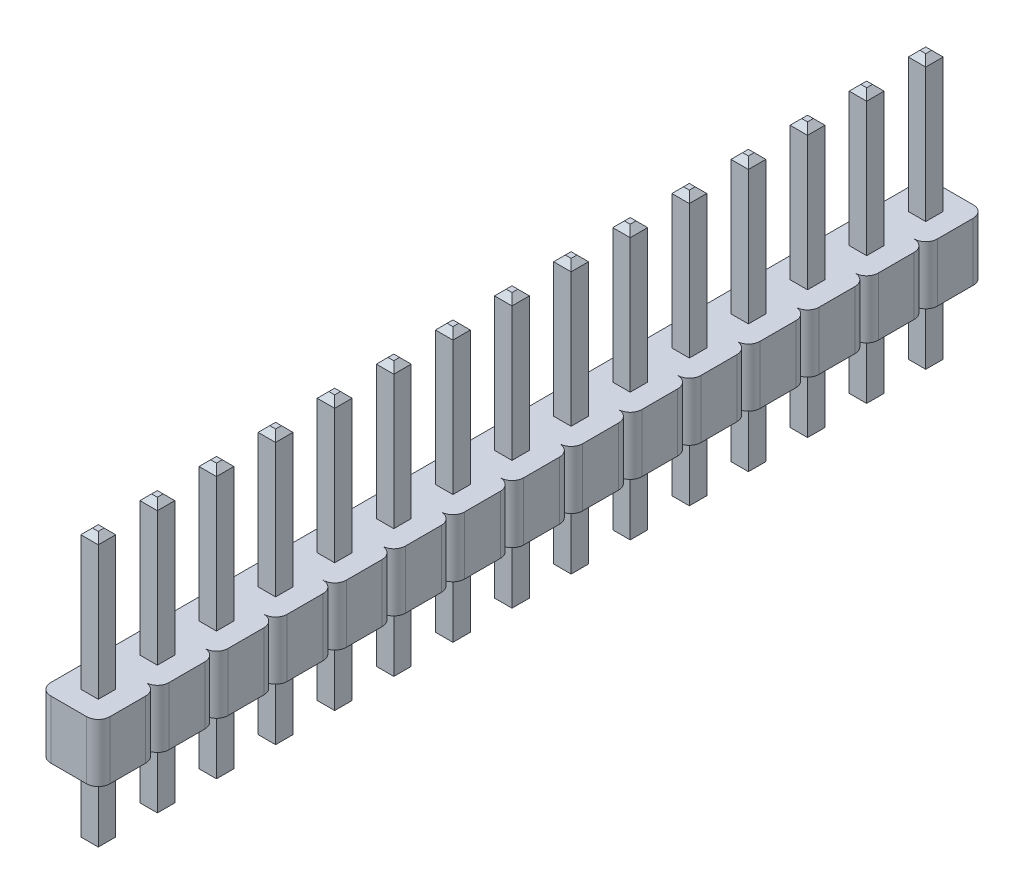
from build123d import *

# Parameters (mm, degrees)
BOSS_EXTRUDE1_DEPTH        = 2.5
LPATTERN1_COUNT            = 15
LPATTERN1_PITCH            = 2.54
BOSS_EXTRUDE2_START        = -3.25
SKETCH2_W                  = 0.75
SKETCH2_H                  = 0.75
BOSS_EXTRUDE2_DEPTH        = 11.75
CHAMFER1_SIZE              = 0.25
LPATTERN2_COUNT            = 15
LPATTERN2_PITCH            = 2.54
CHAMFER1_OF_LPATTERN2_SIZE = 0.25


with BuildPart() as part:
    # Sketch1 → Boss-Extrude1 (new body)
    with BuildSketch(Plane(origin=(0, 0, 0), x_dir=(-1, 0, 0), z_dir=(0, 1, 0))):
        with BuildLine():
            Line((-0.77, 1.27), (0.77, 1.27))
            ThreePointArc((0.77, 1.27), (1.123553391, 1.123553391), (1.27, 0.77))
            Line((1.27, 0.77), (1.27, -0.77))
            ThreePointArc((1.27, -0.77), (1.123553391, -1.123553391), (0.77, -1.27))
            Line((0.77, -1.27), (-0.77, -1.27))
            ThreePointArc((-0.77, -1.27), (-1.123553391, -1.123553391), (-1.27, -0.77))
            Line((-1.27, -0.77), (-1.27, 0.77))
            ThreePointArc((-1.27, 0.77), (-1.123553391, 1.123553391), (-0.77, 1.27))
        make_face()
    boss_extrude1 = extrude(amount=BOSS_EXTRUDE1_DEPTH)

    # LPattern1: Boss-Extrude1 ×15
    with Locations(*[(0, 0, i * LPATTERN1_PITCH) for i in range(1, LPATTERN1_COUNT)]):
        add(boss_extrude1)

    # Sketch2 → Boss-Extrude2 (add)
    with BuildSketch(Plane(origin=(0, 0, 0), x_dir=(-1, 0, 0), z_dir=(0, 1, 0)).offset(BOSS_EXTRUDE2_START)):
        Rectangle(SKETCH2_W, SKETCH2_H)
    boss_extrude2 = extrude(amount=BOSS_EXTRUDE2_DEPTH)

    # Chamfer1
    chamfer1_edges = [part.edges().sort_by_distance(p)[0] for p in [
        (0, -3.25, 0.375),
        (-0.375, -3.25, 0),
        (0.375, -3.25, 0),
        (0, -3.25, -0.375),
        (0, 8.5, 0.375),
        (-0.375, 8.5, 0),
        (0, 8.5, -0.375),
        (0.375, 8.5, 0),
    ]]
    chamfer(chamfer1_edges, length=CHAMFER1_SIZE)

    # LPattern2: Boss-Extrude2 ×15
    with Locations(*[(0, 0, i * LPATTERN2_PITCH) for i in range(1, LPATTERN2_COUNT)]):
        add(boss_extrude2)

    # Chamfer1 of LPattern2
    chamfer1_of_lpattern2_edges = [part.edges().sort_by_distance(p)[0] for p in [
        (0, -3.25, 2.915),
        (-0.375, -3.25, 2.54),
        (0.375, -3.25, 2.54),
        (0, -3.25, 2.165),
        (0, 8.5, 2.915),
        (-0.375, 8.5, 2.54),
        (0, 8.5, 2.165),
        (0.375, 8.5, 2.54),
        (0, -3.25, 5.455),
        (-0.375, -3.25, 5.08),
        (0.375, -3.25, 5.08),
        (0, -3.25, 4.705),
        (0, 8.5, 5.455),
        (-0.375, 8.5, 5.08),
        (0, 8.5, 4.705),
        (0.375, 8.5, 5.08),
        (0, -3.25, 7.995),
        (-0.375, -3.25, 7.62),
        (0.375, -3.25, 7.62),
        (0, -3.25, 7.245),
        (0, 8.5, 7.995),
        (-0.375, 8.5, 7.62),
        (0, 8.5, 7.245),
        (0.375, 8.5, 7.62),
        (0, -3.25, 10.535),
        (-0.375, -3.25, 10.16),
        (0.375, -3.25, 10.16),
        (0, -3.25, 9.785),
        (0, 8.5, 10.535),
        (-0.375, 8.5, 10.16),
        (0, 8.5, 9.785),
        (0.375, 8.5, 10.16),
        (0, -3.25, 13.075),
        (-0.375, -3.25, 12.7),
        (0.375, -3.25, 12.7),
        (0, -3.25, 12.325),
        (0, 8.5, 13.075),
        (-0.375, 8.5, 12.7),
        (0, 8.5, 12.325),
        (0.375, 8.5, 12.7),
        (0, -3.25, 15.615),
        (-0.375, -3.25, 15.24),
        (0.375, -3.25, 15.24),
        (0, -3.25, 14.865),
        (0, 8.5, 15.615),
        (-0.375, 8.5, 15.24),
        (0, 8.5, 14.865),
        (0.375, 8.5, 15.24),
        (0, -3.25, 18.155),
        (-0.375, -3.25, 17.78),
        (0.375, -3.25, 17.78),
        (0, -3.25, 17.405),
        (0, 8.5, 18.155),
        (-0.375, 8.5, 17.78),
        (0, 8.5, 17.405),
        (0.375, 8.5, 17.78),
        (0, -3.25, 20.695),
        (-0.375, -3.25, 20.32),
        (0.375, -3.25, 20.32),
        (0, -3.25, 19.945),
        (0, 8.5, 20.695),
        (-0.375, 8.5, 20.32),
        (0, 8.5, 19.945),
        (0.375, 8.5, 20.32),
        (0, -3.25, 23.235),
        (-0.375, -3.25, 22.86),
        (0.375, -3.25, 22.86),
        (0, -3.25, 22.485),
        (0, 8.5, 23.235),
        (-0.375, 8.5, 22.86),
        (0, 8.5, 22.485),
        (0.375, 8.5, 22.86),
        (0, -3.25, 25.775),
        (-0.375, -3.25, 25.4),
        (0.375, -3.25, 25.4),
        (0, -3.25, 25.025),
        (0, 8.5, 25.775),
        (-0.375, 8.5, 25.4),
        (0, 8.5, 25.025),
        (0.375, 8.5, 25.4),
        (0, -3.25, 28.315),
        (-0.375, -3.25, 27.94),
        (0.375, -3.25, 27.94),
        (0, -3.25, 27.565),
        (0, 8.5, 28.315),
        (-0.375, 8.5, 27.94),
        (0, 8.5, 27.565),
        (0.375, 8.5, 27.94),
        (0, -3.25, 30.855),
        (-0.375, -3.25, 30.48),
        (0.375, -3.25, 30.48),
        (0, -3.25, 30.105),
        (0, 8.5, 30.855),
        (-0.375, 8.5, 30.48),
        (0, 8.5, 30.105),
        (0.375, 8.5, 30.48),
        (0, -3.25, 33.395),
        (-0.375, -3.25, 33.02),
        (0.375, -3.25, 33.02),
        (0, -3.25, 32.645),
        (0, 8.5, 33.395),
        (-0.375, 8.5, 33.02),
        (0, 8.5, 32.645),
        (0.375, 8.5, 33.02),
        (0, -3.25, 35.935),
        (-0.375, -3.25, 35.56),
        (0.375, -3.25, 35.56),
        (0, -3.25, 35.185),
        (0, 8.5, 35.935),
        (-0.375, 8.5, 35.56),
        (0, 8.5, 35.185),
        (0.375, 8.5, 35.56),
    ]]
    chamfer(chamfer1_of_lpattern2_edges, length=CHAMFER1_OF_LPATTERN2_SIZE)


solid = part.part
